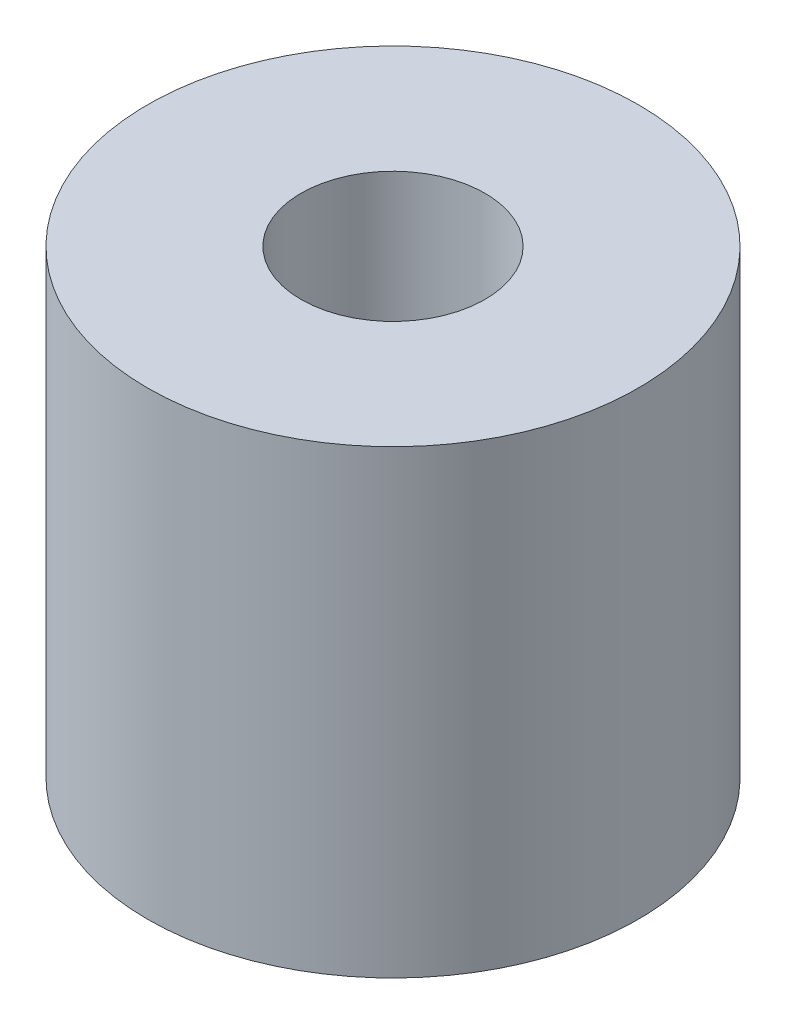
from build123d import *

# Parameters (mm, degrees)
SKETCH1_R           = 1.6
SKETCH1_R_2         = 0.6
BOSS_EXTRUDE1_DEPTH = 3


with BuildPart() as part:
    # Sketch1 → Boss-Extrude1 (new body)
    with BuildSketch(Plane(origin=(0, 0, 0), x_dir=(1, 0, 0), z_dir=(0, 1, 0))):
        Circle(SKETCH1_R)
        Circle(SKETCH1_R_2, mode=Mode.SUBTRACT)
    extrude(amount=BOSS_EXTRUDE1_DEPTH)


solid = part.part
